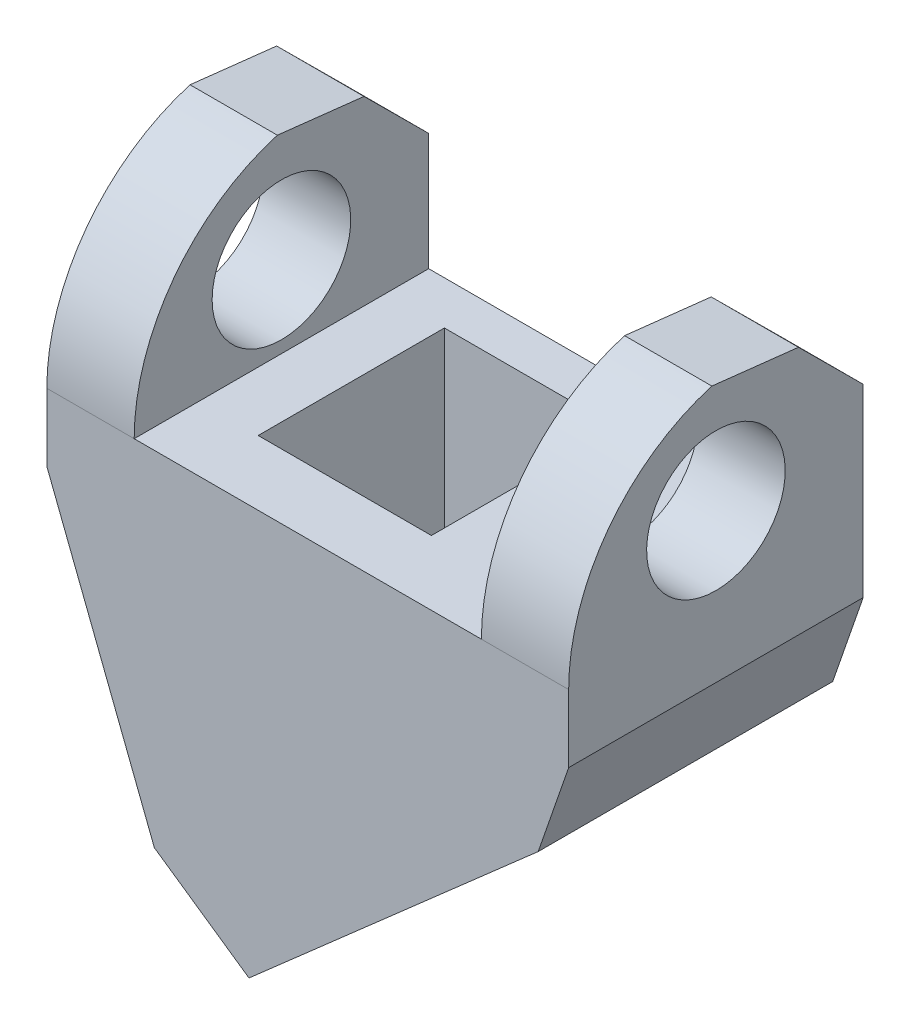
from build123d import *

# Parameters (mm, degrees)
BOSS_EXTRUDE1_DEPTH     = 17
CUT_EXTRUDE1_DEPTH      = 44
CUT_EXTRUDE1_DEPTH_BACK = 15
SKETCH3_W               = 9.473572921
SKETCH3_H               = 10.746142417
CUT_EXTRUDE4_REACH      = 25.646
SKETCH5_W               = 10
SKETCH5_H               = 10.75
SKETCH6_R               = 4
CUT_EXTRUDE5_DEPTH      = 16.063287133
CUT_EXTRUDE5_DEPTH_BACK = 16.059572792


with BuildPart() as part:
    # Sketch1 → Boss-Extrude1 (new body)
    with BuildSketch(Plane.XY):
        Polygon((-30.543999746, 100.861422718), (-25.501974605, 100.861422718), (-25.501974605, 89.763425291), (-5.459450623, 89.763425291), (-5.459450623, 100.861422718), (-0.421139822, 100.861422718), (-0.421139822, 85.861422718), (-2.179573068, 80.78462442), (-18.874125124, 66.117800283), (-24.336952566, 69.899502921), (-30.543999746, 85.861422718), align=None)
    extrude(amount=BOSS_EXTRUDE1_DEPTH)

    # Sketch2 → Cut-Extrude1 (cut, two sides)
    with BuildSketch(Plane(origin=(-25.501974605, 0, 0), x_dir=(0, 0, -1), z_dir=(1, 0, 0))) as cut_extrude1_sk:
        with BuildLine():
            Line((-17, 100.861422718), (-17, 89.763425291))
            ThreePointArc((-17, 89.763425291), (-14.704510799, 96.659236925), (-8.73400026, 100.803448872))
            Line((-8.73400026, 100.803448872), (-3.73400026, 100.241430104))
            Line((-3.73400026, 100.241430104), (0, 96.527419984))
            Line((0, 96.527419984), (0, 100.861422718))
            Line((0, 100.861422718), (-17, 100.861422718))
        make_face()
    extrude(amount=CUT_EXTRUDE1_DEPTH, mode=Mode.SUBTRACT)
    extrude(cut_extrude1_sk.sketch, amount=-CUT_EXTRUDE1_DEPTH_BACK, mode=Mode.SUBTRACT)

    # Cut-Sweep1: sweep along a path in Sketch4
    with BuildLine(Plane.XY.offset(10)) as cut_sweep1_path:
        Line((-14.80649526, 69.691373965), (-22.116585307, 75.218908697))
    # Sketch3 → Cut-Sweep1 (sweep, cut)
    with BuildSketch(Plane(origin=(-41.005446227, 46.67455955, 0), x_dir=(0.7512574, 0.660009333, 0), z_dir=(0.660009333, -0.7512574, 0))):
        with Locations((38.216319794, 7.888020567)):
            Rectangle(SKETCH3_W, SKETCH3_H)
    sweep(path=cut_sweep1_path.line, mode=Mode.SUBTRACT)

    # Cut-Extrude4: up to this face of the body (flat: up to its plane)
    cut_extrude4_end = Plane(part.part.faces().sort_by_distance((-19.508744094, 71.535131374, 7.888020567))[0])
    # Sketch5 → Cut-Extrude4 (cut, up to the picked face)
    with BuildSketch(Plane(origin=(0, 89.763425291, 0), x_dir=(1, 0, 0), z_dir=(0, 1, 0)), mode=Mode.PRIVATE) as cut_extrude4_sk1:
        with Locations((-17.083999746, -7.885)):
            Rectangle(SKETCH5_W, SKETCH5_H)
    cut_extrude4_tool1 = split(extrude(cut_extrude4_sk1.sketch, amount=-CUT_EXTRUDE4_REACH, mode=Mode.PRIVATE), bisect_by=cut_extrude4_end, keep=Keep.BOTH, mode=Mode.PRIVATE)
    add(cut_extrude4_tool1.solids().sort_by_distance((-17.084, 89.763425, 7.885))[0], mode=Mode.SUBTRACT)

    # Sketch6 → Cut-Extrude5 (cut, two sides)
    with BuildSketch(Plane.ZY.offset(15.480712614)) as cut_extrude5_sk:
        with Locations((8.5, 94.459280843)):
            Circle(SKETCH6_R)
    extrude(amount=CUT_EXTRUDE5_DEPTH, mode=Mode.SUBTRACT)
    extrude(cut_extrude5_sk.sketch, amount=-CUT_EXTRUDE5_DEPTH_BACK, mode=Mode.SUBTRACT)


solid = part.part
